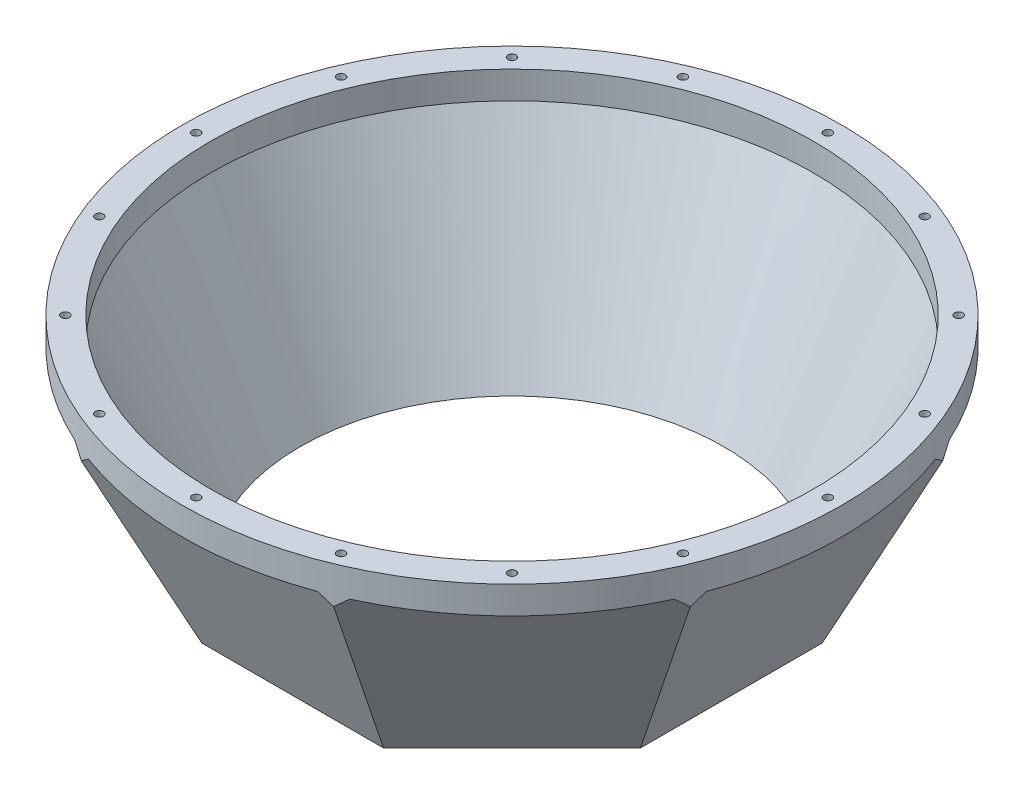
from build123d import *

# Parameters (mm, degrees)
SKETCH3_R           = 152.4
BOSS_EXTRUDE1_DEPTH = 101.6
CUT_EXTRUDE1_DEPTH  = 153.4
CIRPATTERN1_COUNT   = 8
CIRPATTERN2_COUNT   = 16


with BuildPart() as part:
    # Sketch3 → Boss-Extrude1 (new body)
    with BuildSketch(Plane(origin=(0, 0, 0), x_dir=(1, 0, 0), z_dir=(0, 1, 0))):
        Circle(SKETCH3_R)
    extrude(amount=BOSS_EXTRUDE1_DEPTH)

    # Sketch4 → Cut-Extrude1 (cut, symmetric)
    with BuildSketch(Plane.XY):
        Polygon((142.875, 88.9), (101.42024919, 0), (152.4, 0), (152.4, 88.9), align=None)
    cut_extrude1 = extrude(amount=CUT_EXTRUDE1_DEPTH, both=True, mode=Mode.SUBTRACT)

    # CirPattern1: Cut-Extrude1 ×8 about axis
    cirpattern1_axis = Axis((0, 0, 0), (0, 1, 0))
    for i in range(1, CIRPATTERN1_COUNT):
        add(cut_extrude1.rotate(cirpattern1_axis, i * 360 / CIRPATTERN1_COUNT), mode=Mode.SUBTRACT)

    # Sketch7 → Cut-Revolve1 (revolve, cut)
    with BuildSketch(Plane.XY):
        Polygon((97.917024297, 0), (139.371775107, 88.9), (139.371775107, 101.6), (0, 101.6), (0, 0), align=None)
    revolve(axis=Axis((0, 101.6, 0), (0, -1, 0)), mode=Mode.SUBTRACT)

    # Sketch9 → #10-24 Tapped Hole1 (revolve, cut)
    with BuildSketch(Plane(origin=(146.05, 101.6, 0), x_dir=(0, 0, 1), z_dir=(1, 0, 0))):
        Polygon((0, 0), (0, 14.094824014), (1.89865, 12.954), (1.89865, 0), align=None)
    f_10_24_tapped_hole1 = revolve(axis=Axis((146.05, 107.95, 0), (0, -1, 0)), mode=Mode.SUBTRACT)

    # CirPattern2: #10-24 Tapped Hole1 ×16 about axis
    cirpattern2_axis = Axis((0, 0, 0), (0, 1, 0))
    for i in range(1, CIRPATTERN2_COUNT):
        add(f_10_24_tapped_hole1.rotate(cirpattern2_axis, i * 360 / CIRPATTERN2_COUNT), mode=Mode.SUBTRACT)


solid = part.part
